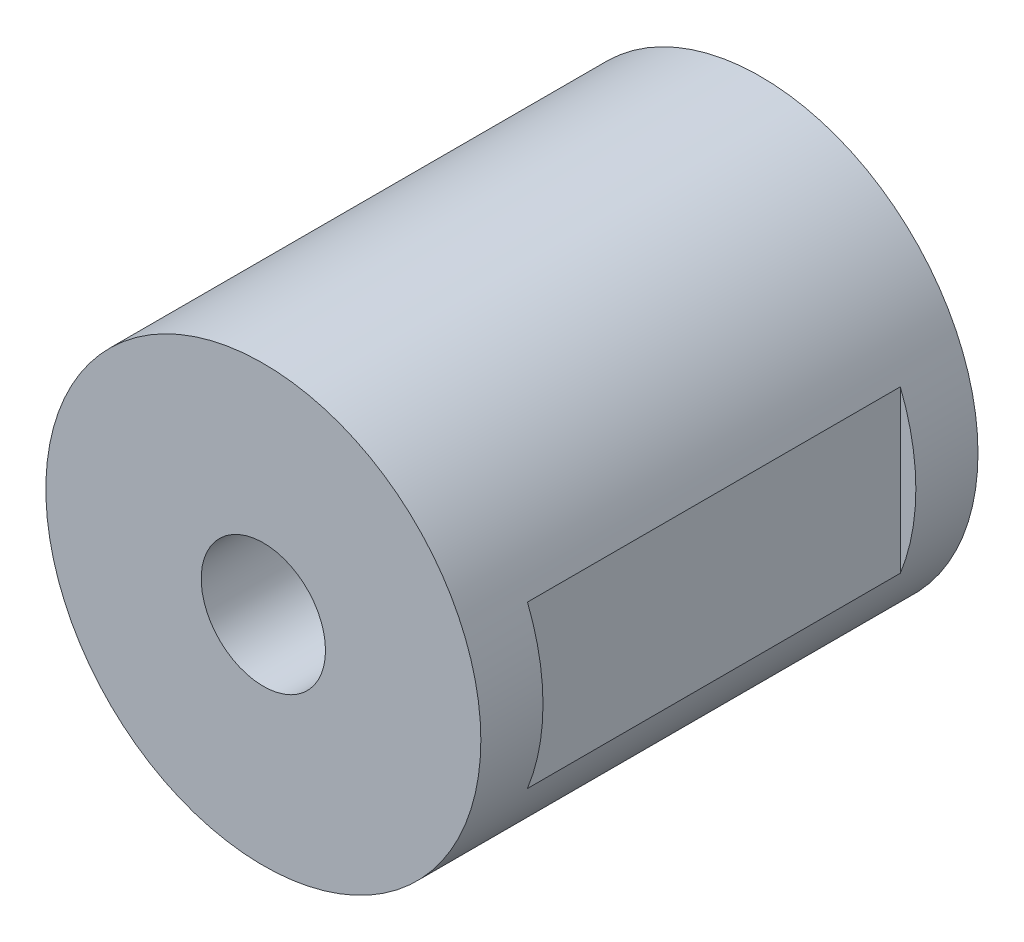
from build123d import *

# Parameters (mm, degrees)
SKETCH1_R           = 35
BOSS_EXTRUDE1_DEPTH = 80
SKETCH2_R           = 10
CUT_EXTRUDE1_DEPTH  = 81
SKETCH3_W           = 60
SKETCH3_H           = 25.98
CUT_EXTRUDE5_DEPTH  = 2.5
SKETCH4_W           = 36.06
SKETCH4_H           = 40
CUT_EXTRUDE6_DEPTH  = 5


with BuildPart() as part:
    # Sketch1 → Boss-Extrude1 (new body)
    with BuildSketch(Plane.XY):
        Circle(SKETCH1_R)
    extrude(amount=BOSS_EXTRUDE1_DEPTH)

    # Sketch2 → Cut-Extrude1 (cut, through all)
    with BuildSketch(Plane.XY.offset(80)):
        Circle(SKETCH2_R)
    extrude(amount=-CUT_EXTRUDE1_DEPTH, mode=Mode.SUBTRACT)

    # Sketch3 → Cut-Extrude5 (cut)
    with BuildSketch(Plane(origin=(35, 0, 0), x_dir=(0, 0, -1), z_dir=(1, 0, 0))):
        with Locations((-40, 0)):
            Rectangle(SKETCH3_W, SKETCH3_H)
    extrude(amount=-CUT_EXTRUDE5_DEPTH, mode=Mode.SUBTRACT)

    # Sketch4 → Cut-Extrude6 (cut)
    with BuildSketch(Plane(origin=(0, -35, 0), x_dir=(-1, 0, 0), z_dir=(0, -1, 0))):
        with Locations((0, -40)):
            Rectangle(SKETCH4_W, SKETCH4_H)
    extrude(amount=-CUT_EXTRUDE6_DEPTH, mode=Mode.SUBTRACT)


solid = part.part
